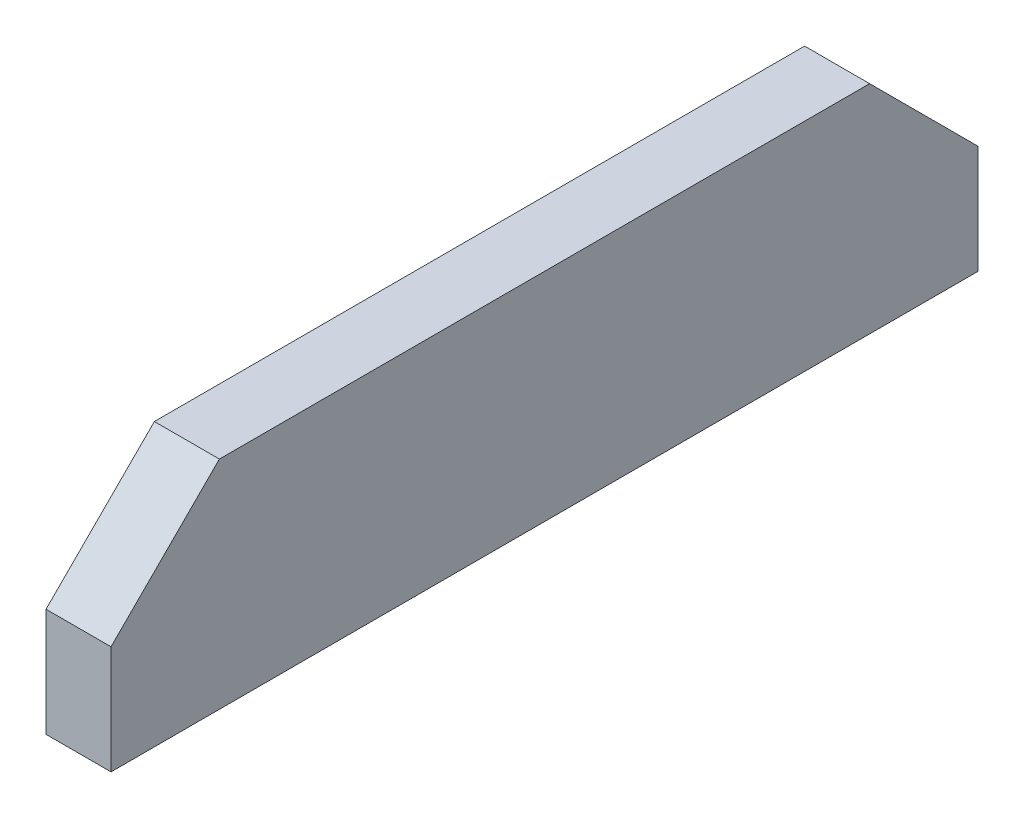
from build123d import *

# Parameters (mm, degrees)
EXTRUDE_1_DEPTH = 3


with BuildPart() as part:
    # Эскиз1 → Бобышка-Вытянуть1 (new body)
    with BuildSketch(Plane(origin=(0, 0, 0), x_dir=(0, 0, -1), z_dir=(1, 0, 0))):
        Polygon((0, 0), (40, 0), (40, 5), (35, 10), (5, 10), (0, 5), align=None)
    extrude(amount=EXTRUDE_1_DEPTH)


solid = part.part
